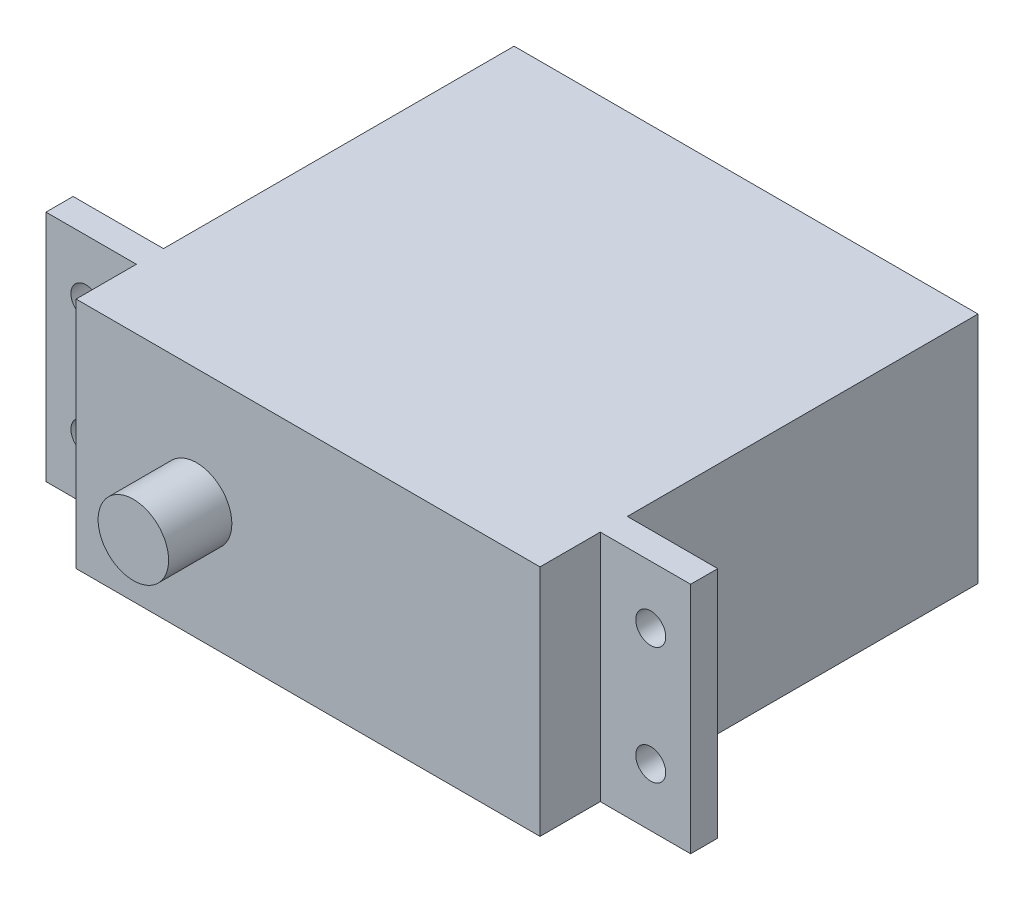
from build123d import *

# Parameters (mm, degrees)
SKETCH1_W                        = 54.356
SKETCH1_H                        = 19.685
EXTRUDE1_DEPTH                   = 42.2656
SKETCH3_OUTSIDE_W                = 70.678
SKETCH3_OUTSIDE_H                = 36.007
SKETCH3_OUTSIDE_R                = 2.9718
EXTRUDE2_DEPTH                   = 5.334
SKETCH7_W                        = 7.62
SKETCH7_H                        = 20.335773086
SKETCH7_H_2                      = 19.919316746
EXTRUDE4_DEPTH                   = 10.414
SKETCH8_W                        = 7.62
SKETCH8_H                        = 19.792977092
SKETCH8_H_2                      = 19.986836906
EXTRUDE5_DEPTH                   = 29.5656
F_39_0_0995_DIAMETER_HOLE1_D     = 2.5273
F_39_0_0995_DIAMETER_HOLE1_DEPTH = 12.7
F_39_0_0995_DIAMETER_HOLE1_TIP   = 0.759277521


with BuildPart() as part:
    # Sketch1 → Extrude1 (new body)
    with BuildSketch(Plane.XY):
        Rectangle(SKETCH1_W, SKETCH1_H)
    extrude(amount=EXTRUDE1_DEPTH)

    # Sketch3 outside → Extrude2 (cut)
    with BuildSketch(Plane.XY.offset(42.2656)):
        with Locations((0, 0.0005)):
            Rectangle(SKETCH3_OUTSIDE_W, SKETCH3_OUTSIDE_H)
        with Locations((-9.398, 0)):
            Circle(SKETCH3_OUTSIDE_R, mode=Mode.SUBTRACT)
    extrude(amount=-EXTRUDE2_DEPTH, mode=Mode.SUBTRACT)

    # Sketch7 → Extrude4 (cut)
    with BuildSketch(Plane.XY.offset(42.2656)):
        with Locations((23.368, 0)):
            Rectangle(SKETCH7_W, SKETCH7_H)
        with Locations((-23.368, 0)):
            Rectangle(SKETCH7_W, SKETCH7_H_2)
    extrude(amount=-EXTRUDE4_DEPTH, mode=Mode.SUBTRACT)

    # Sketch8 → Extrude5 (cut)
    with BuildSketch(Plane(origin=(0, 0, 0), x_dir=(-1, 0, 0), z_dir=(0, 0, -1))):
        with Locations((23.368, 0)):
            Rectangle(SKETCH8_W, SKETCH8_H)
        with Locations((-23.368, 0)):
            Rectangle(SKETCH8_W, SKETCH8_H_2)
    extrude(amount=-EXTRUDE5_DEPTH, mode=Mode.SUBTRACT)

    # #39 (0.0995) Diameter Hole1
    with Locations(Plane(origin=(-23.8125, 4.953, 31.8516), x_dir=(1, 0, 0), z_dir=(0, 0, 1))):
        with Locations((0, 0), (0, -9.906), (47.625, 0), (47.625, -9.906)):
            Hole(F_39_0_0995_DIAMETER_HOLE1_D / 2, depth=F_39_0_0995_DIAMETER_HOLE1_DEPTH)
            with Locations((0, 0, -(F_39_0_0995_DIAMETER_HOLE1_DEPTH + F_39_0_0995_DIAMETER_HOLE1_TIP / 2))):  # 118° drill point
                Cone(0, F_39_0_0995_DIAMETER_HOLE1_D / 2, F_39_0_0995_DIAMETER_HOLE1_TIP, mode=Mode.SUBTRACT)


solid = part.part
